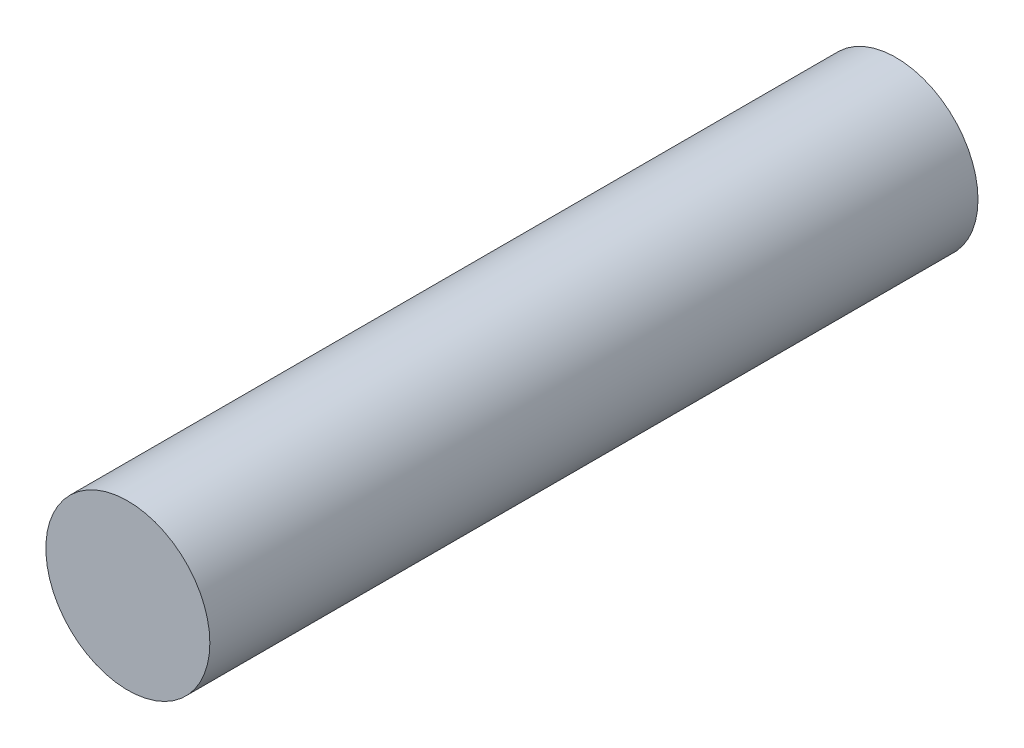
from build123d import *

# Parameters (mm, degrees)
SKETCH1_R           = 3
BOSS_EXTRUDE1_DEPTH = 28.1


with BuildPart() as part:
    # Sketch1 → Boss-Extrude1 (new body)
    with BuildSketch(Plane.XY):
        Circle(SKETCH1_R)
    extrude(amount=BOSS_EXTRUDE1_DEPTH)


solid = part.part
